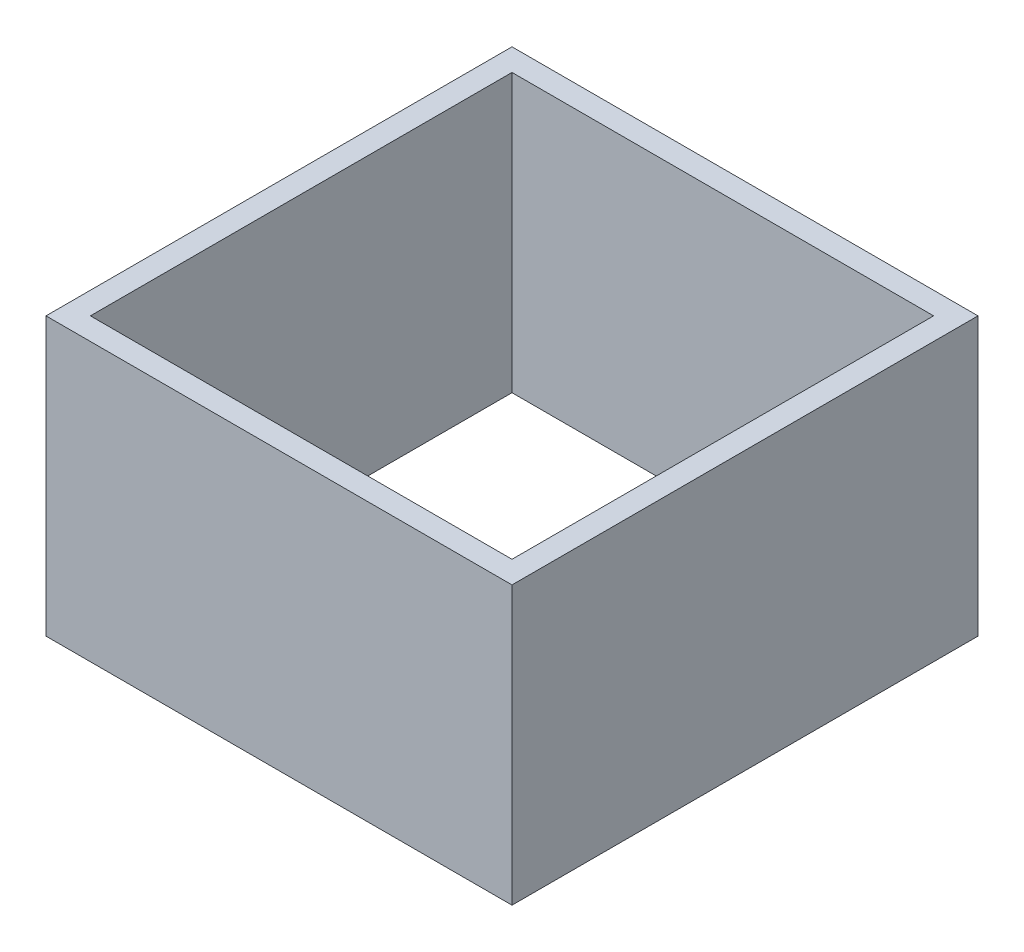
from build123d import *

# Parameters (mm, degrees)
SKETCH1_W           = 42
SKETCH1_H           = 42
SKETCH1_W_2         = 38
SKETCH1_H_2         = 38
BOSS_EXTRUDE1_DEPTH = 25


with BuildPart() as part:
    # Sketch1 → Boss-Extrude1 (new body)
    with BuildSketch(Plane(origin=(0, 0, 0), x_dir=(1, 0, 0), z_dir=(0, 1, 0))):
        Rectangle(SKETCH1_W, SKETCH1_H)
        Rectangle(SKETCH1_W_2, SKETCH1_H_2, mode=Mode.SUBTRACT)
    extrude(amount=BOSS_EXTRUDE1_DEPTH)


solid = part.part
